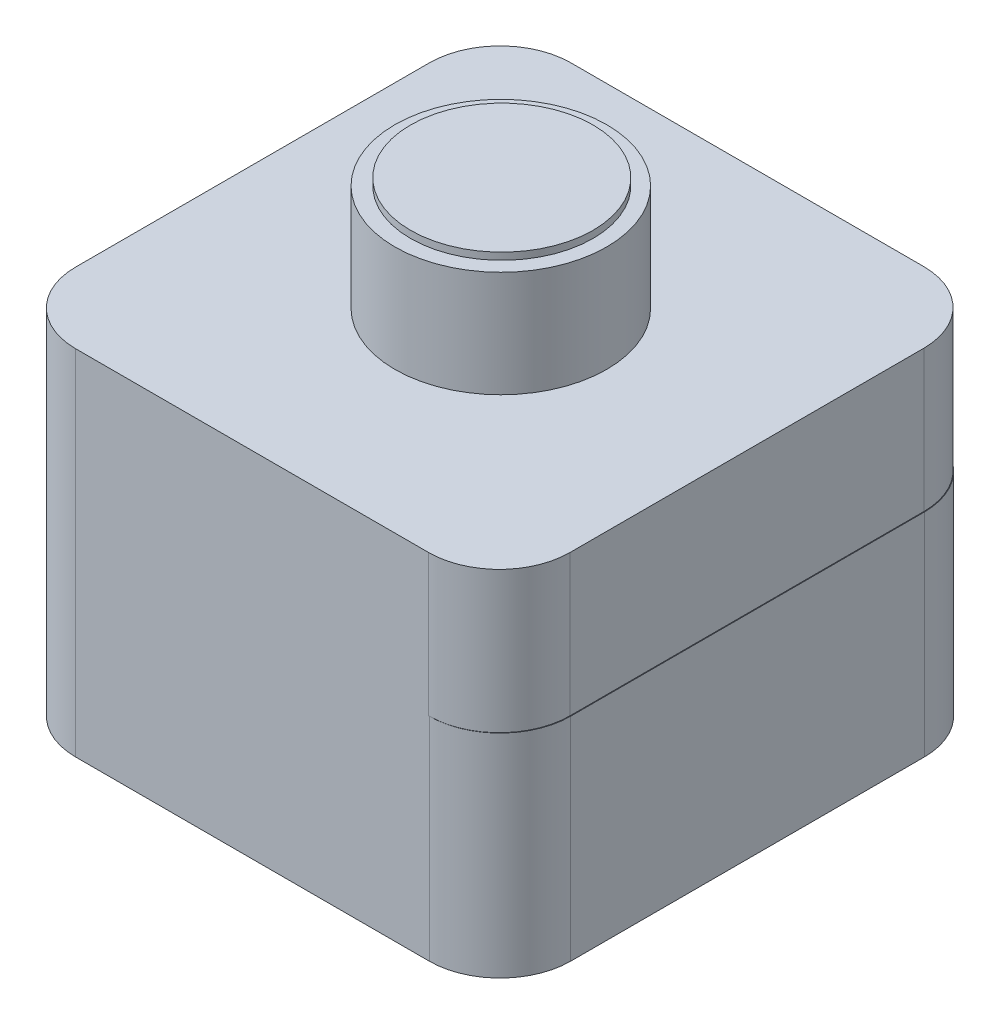
from build123d import *

# Parameters (mm, degrees)
SALIENTE_EXTRUIR1_DEPTH = 30
SALIENTE_EXTRUIR2_DEPTH = 20
SALIENTE_EXTRUIR3_DEPTH = 15
SALIENTE_EXTRUIR4_DEPTH = 1


with BuildPart() as part:
    # Croquis1 → Saliente-Extruir1 (new body)
    with BuildSketch(Plane(origin=(0, 0, 0), x_dir=(1, 0, 0), z_dir=(0, 1, 0))):
        with BuildLine():
            Line((10, 0), (60, 0))
            ThreePointArc((60, 0), (67.071067812, 2.928932188), (70, 10))
            Line((70, 10), (70, 60))
            ThreePointArc((70, 60), (67.071067812, 67.071067812), (60, 70))
            Line((60, 70), (10, 70))
            ThreePointArc((10, 70), (2.928932188, 67.071067812), (0, 60))
            Line((0, 60), (0, 10))
            ThreePointArc((0, 10), (2.928932188, 2.928932188), (10, 0))
        make_face()
    extrude(amount=SALIENTE_EXTRUIR1_DEPTH)

    # Croquis2 → Saliente-Extruir2 (add)
    with BuildSketch(Plane(origin=(0, 30, 0), x_dir=(1, 0, 0), z_dir=(0, 1, 0))):
        with BuildLine():
            Line((10, 0), (59.904487732, 0))
            ThreePointArc((59.904487732, 0), (66.975555544, 2.928932188), (69.904487732, 10))
            Line((69.904487732, 10), (69.904487732, 60.022676449))
            ThreePointArc((69.904487732, 60.022676449), (66.975555544, 67.093744261), (59.904487732, 70.022676449))
            Line((59.904487732, 70.022676449), (10, 70.022676449))
            ThreePointArc((10, 70.022676449), (2.928932188, 67.093744261), (0, 60.022676449))
            Line((0, 60.022676449), (0, 10))
            ThreePointArc((0, 10), (2.928932188, 2.928932188), (10, 0))
        make_face()
    extrude(amount=SALIENTE_EXTRUIR2_DEPTH)

    # Croquis3 → Saliente-Extruir3 (add)
    with BuildSketch(Plane(origin=(0, 50, 0), x_dir=(1, 0, 0), z_dir=(0, 1, 0))):
        with BuildLine():
            ThreePointArc((45.714988655, 45.583878221), (35.109068959, 49.985918595), (24.503149262, 45.583878221))
            Line((24.503149262, 45.583878221), (35.109068959, 35.008376267))
            Line((35.109068959, 35.008376267), (45.714988655, 45.583878221))
        make_face()
        with BuildLine():
            Line((35.109068959, 35.008376267), (24.503149262, 45.583878221))
            ThreePointArc((24.503149262, 45.583878221), (20.131526631, 35.008376267), (24.503149262, 24.432874313))
            Line((24.503149262, 24.432874313), (35.109068959, 35.008376267))
        make_face()
        with BuildLine():
            Line((45.714988655, 45.583878221), (35.109068959, 35.008376267))
            Line((35.109068959, 35.008376267), (45.714988655, 24.432874313))
            ThreePointArc((45.714988655, 24.432874313), (48.950625688, 29.286656114), (50.086611287, 35.008376267))
            ThreePointArc((50.086611287, 35.008376267), (48.950625688, 40.730096419), (45.714988655, 45.583878221))
        make_face()
        with BuildLine():
            Line((45.714988655, 24.432874313), (35.109068959, 35.008376267))
            Line((35.109068959, 35.008376267), (24.503149262, 24.432874313))
            ThreePointArc((24.503149262, 24.432874313), (35.109068959, 20.030833939), (45.714988655, 24.432874313))
        make_face()
    extrude(amount=SALIENTE_EXTRUIR3_DEPTH)

    # Croquis4 → Saliente-Extruir4 (add)
    with BuildSketch(Plane(origin=(0, 65, 0), x_dir=(1, 0, 0), z_dir=(0, 1, 0))):
        with BuildLine():
            ThreePointArc((26.040054757, 25.966127976), (35.178980063, 22.173048991), (44.317905369, 25.966127976))
            Line((44.317905369, 25.966127976), (35.178980063, 35.079108201))
            Line((35.178980063, 35.079108201), (26.040054757, 25.966127976))
        make_face()
        with BuildLine():
            Line((35.178980063, 35.079108201), (44.317905369, 25.966127976))
            ThreePointArc((44.317905369, 25.966127976), (47.106131346, 30.148649135), (48.085039273, 35.079108201))
            ThreePointArc((48.085039273, 35.079108201), (47.106131346, 40.009567268), (44.317905369, 44.192088426))
            Line((44.317905369, 44.192088426), (35.178980063, 35.079108201))
        make_face()
        with BuildLine():
            Line((26.040054757, 25.966127976), (35.178980063, 35.079108201))
            Line((35.178980063, 35.079108201), (26.040054757, 44.192088426))
            ThreePointArc((26.040054757, 44.192088426), (22.272920853, 35.079108201), (26.040054757, 25.966127976))
        make_face()
        with BuildLine():
            Line((26.040054757, 44.192088426), (35.178980063, 35.079108201))
            Line((35.178980063, 35.079108201), (44.317905369, 44.192088426))
            ThreePointArc((44.317905369, 44.192088426), (35.178980063, 47.985167411), (26.040054757, 44.192088426))
        make_face()
    extrude(amount=SALIENTE_EXTRUIR4_DEPTH)


solid = part.part
